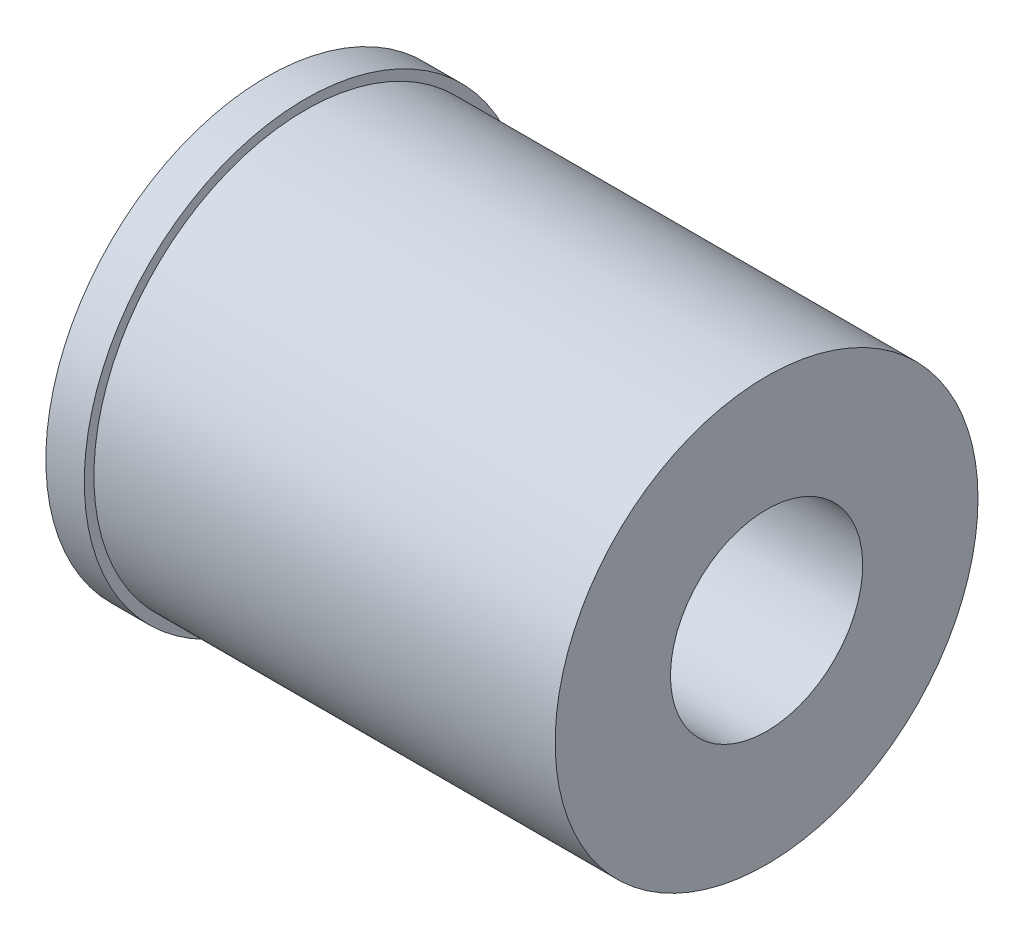
from build123d import *

# Parameters (mm, degrees)
SKETCH_2_R          = 2.5
CUT_EXTRUDE_1_DEPTH = 14


with BuildPart() as part:
    # ｽｹｯﾁ1 → 回転1 (revolve)
    with BuildSketch(Plane.XY):
        Polygon((0, 0), (-13, 0), (-13, 5.75), (-12, 5.75), (-12, 5.5), (0, 5.5), align=None)
    revolve(axis=Axis((0, 0, 0), (-1, 0, 0)))

    # ｽｹｯﾁ2 → ｶｯﾄ - 押し出し1 (cut, through all)
    with BuildSketch(Plane.ZY.offset(13)):
        Circle(SKETCH_2_R)
    extrude(amount=-CUT_EXTRUDE_1_DEPTH, mode=Mode.SUBTRACT)


solid = part.part
